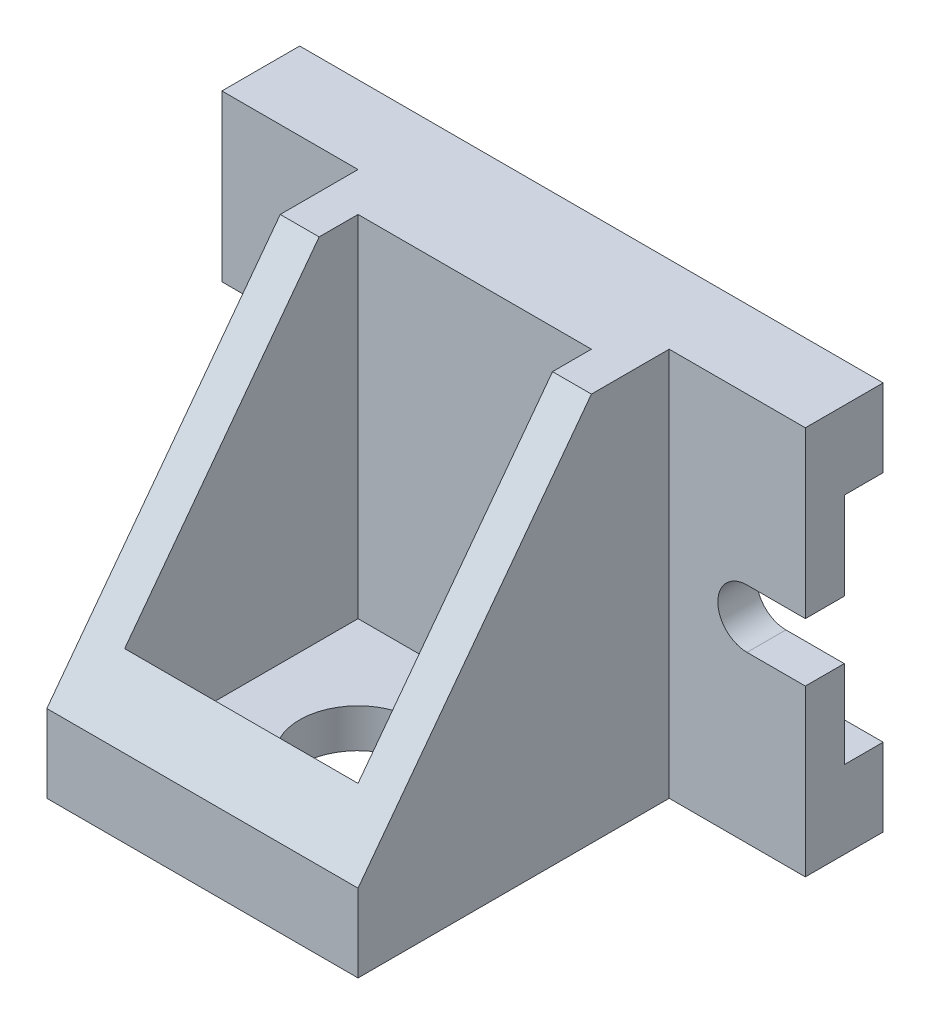
from build123d import *

# Parameters (mm, degrees)
SALIENTE_EXTRUIR1_DEPTH    = 20
CROQUIS3_W                 = 10
CROQUIS3_H                 = 60
CORTAR_EXTRUIR1_DEPTH      = 1
CORTAR_EXTRUIR1_DEPTH_BACK = 151
SALIENTE_EXTRUIR2_DEPTH    = 150
CROQUIS6_W                 = 80
CROQUIS6_H                 = 100
CORTAR_EXTRUIR2_DEPTH      = 1
CORTAR_EXTRUIR2_DEPTH_BACK = 35
CROQUIS7_W                 = 80
CROQUIS7_H                 = 100
CORTAR_EXTRUIR3_DEPTH      = 35
CROQUIS8_W                 = 60
CROQUIS8_H                 = 60
CORTAR_EXTRUIR4_DEPTH      = 90
CROQUIS9_R                 = 15
CORTAR_EXTRUIR5_DEPTH      = 101


with BuildPart() as part:
    # Croquis2 → Saliente-Extruir1 (new body)
    with BuildSketch(Plane.XY):
        with BuildLine():
            Line((-75, 50), (75, 50))
            Line((75, 50), (75, 7.5))
            Line((75, 7.5), (60, 7.5))
            ThreePointArc((60, 7.5), (52.5, 0), (60, -7.5))
            Line((60, -7.5), (75, -7.5))
            Line((75, -7.5), (75, -50))
            Line((75, -50), (-75, -50))
            Line((-75, -50), (-75, -7.5))
            Line((-75, -7.5), (-60, -7.5))
            ThreePointArc((-60, -7.5), (-52.5, 0), (-60, 7.5))
            Line((-60, 7.5), (-75, 7.5))
            Line((-75, 7.5), (-75, 50))
        make_face()
    extrude(amount=SALIENTE_EXTRUIR1_DEPTH)

    # Croquis3 → Cortar-Extruir1 (cut, two sides)
    with BuildSketch(Plane.ZY.offset(75)) as cortar_extruir1_sk:
        with Locations((5, 0)):
            Rectangle(CROQUIS3_W, CROQUIS3_H)
    extrude(amount=CORTAR_EXTRUIR1_DEPTH, mode=Mode.SUBTRACT)
    extrude(cortar_extruir1_sk.sketch, amount=-CORTAR_EXTRUIR1_DEPTH_BACK, mode=Mode.SUBTRACT)

    # Croquis5 → Saliente-Extruir2 (add, through all)
    with BuildSketch(Plane(origin=(75, 0, 0), x_dir=(0, 0, -1), z_dir=(1, 0, 0))):
        Polygon((-40, 50), (-20, 50), (-20, -50), (-40, -50), (-100, -50), (-100, -30), align=None)
    extrude(amount=-SALIENTE_EXTRUIR2_DEPTH)

    # Croquis6 → Cortar-Extruir2 (cut, two sides)
    with BuildSketch(Plane(origin=(75, 0, 0), x_dir=(0, 0, -1), z_dir=(1, 0, 0))) as cortar_extruir2_sk:
        with Locations((-60, 0)):
            Rectangle(CROQUIS6_W, CROQUIS6_H)
    extrude(amount=CORTAR_EXTRUIR2_DEPTH, mode=Mode.SUBTRACT)
    extrude(cortar_extruir2_sk.sketch, amount=-CORTAR_EXTRUIR2_DEPTH_BACK, mode=Mode.SUBTRACT)

    # Croquis7 → Cortar-Extruir3 (cut)
    with BuildSketch(Plane.ZY.offset(75)):
        with Locations((60, 0)):
            Rectangle(CROQUIS7_W, CROQUIS7_H)
    extrude(amount=-CORTAR_EXTRUIR3_DEPTH, mode=Mode.SUBTRACT)

    # Croquis8 → Cortar-Extruir4 (cut)
    with BuildSketch(Plane(origin=(0, 50, 0), x_dir=(1, 0, 0), z_dir=(0, 1, 0))):
        with Locations((0, -60)):
            Rectangle(CROQUIS8_W, CROQUIS8_H)
    extrude(amount=-CORTAR_EXTRUIR4_DEPTH, mode=Mode.SUBTRACT)

    # Croquis9 → Cortar-Extruir5 (cut, through all)
    with BuildSketch(Plane(origin=(0, 50, 0), x_dir=(1, 0, 0), z_dir=(0, 1, 0))):
        with Locations((0, -60)):
            Circle(CROQUIS9_R)
    extrude(amount=-CORTAR_EXTRUIR5_DEPTH, mode=Mode.SUBTRACT)


solid = part.part
